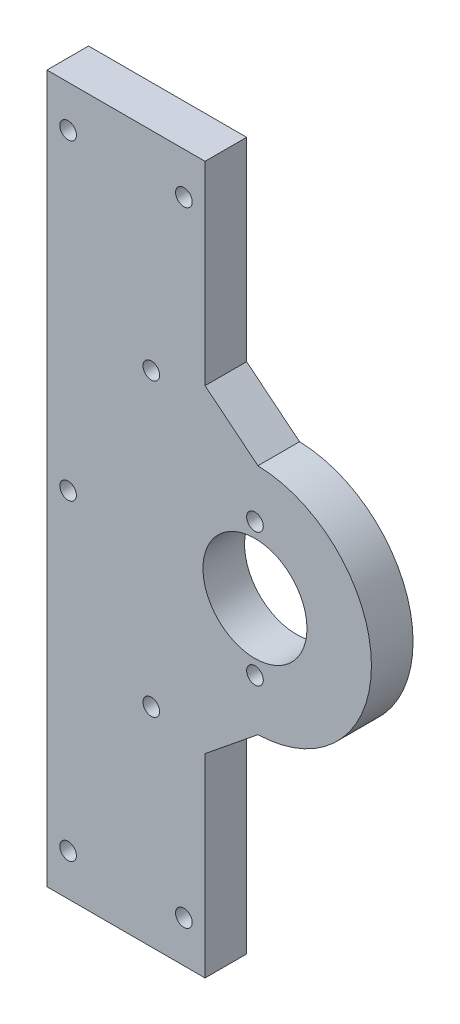
from build123d import *

# Parameters (mm, degrees)
SKETCH1_R           = 2
SKETCH1_R_2         = 12.5
BOSS_EXTRUDE1_DEPTH = 10


with BuildPart() as part:
    # Sketch1 → Boss-Extrude1 (new body)
    with BuildSketch(Plane.XY):
        with BuildLine():
            Line((-1.000028724, -38.297888442), (11.718065373, -27.990486171))
            ThreePointArc((11.718065373, -27.990486171), (39.000028724, 0.00030559), (11.718065373, 27.99109735))
            Line((11.718065373, 27.99109735), (-1.000028724, 38.298499621))
            Line((-1.000028724, 38.298499621), (-1.000028724, 85))
            Line((-1.000028724, 85), (-39.000028724, 85))
            Line((-39.000028724, 85), (-39.000028724, -85))
            Line((-39.000028724, -85), (-1.000028724, -85))
            Line((-1.000028724, -85), (-1.000028724, -38.297888442))
        make_face()
        with Locations((-13.916259829, -35)):
            Circle(SKETCH1_R, mode=Mode.SUBTRACT)
        with Locations((-13.916259829, 35)):
            Circle(SKETCH1_R, mode=Mode.SUBTRACT)
        with Locations((11.000028724, 0.00030559)):
            Circle(SKETCH1_R_2, mode=Mode.SUBTRACT)
        with Locations((-6.083797619, 75)):
            Circle(SKETCH1_R, mode=Mode.SUBTRACT)
        with Locations((-6.083797619, -75)):
            Circle(SKETCH1_R, mode=Mode.SUBTRACT)
        with Locations((-33.916259829, 75)):
            Circle(SKETCH1_R, mode=Mode.SUBTRACT)
        with Locations((-33.916259829, 0)):
            Circle(SKETCH1_R, mode=Mode.SUBTRACT)
        with Locations((11.000028724, -15.99969441)):
            Circle(SKETCH1_R, mode=Mode.SUBTRACT)
        with Locations((11.000028724, 16.00030559)):
            Circle(SKETCH1_R, mode=Mode.SUBTRACT)
        with Locations((-33.916259829, -75)):
            Circle(SKETCH1_R, mode=Mode.SUBTRACT)
    extrude(amount=BOSS_EXTRUDE1_DEPTH)


solid = part.part
